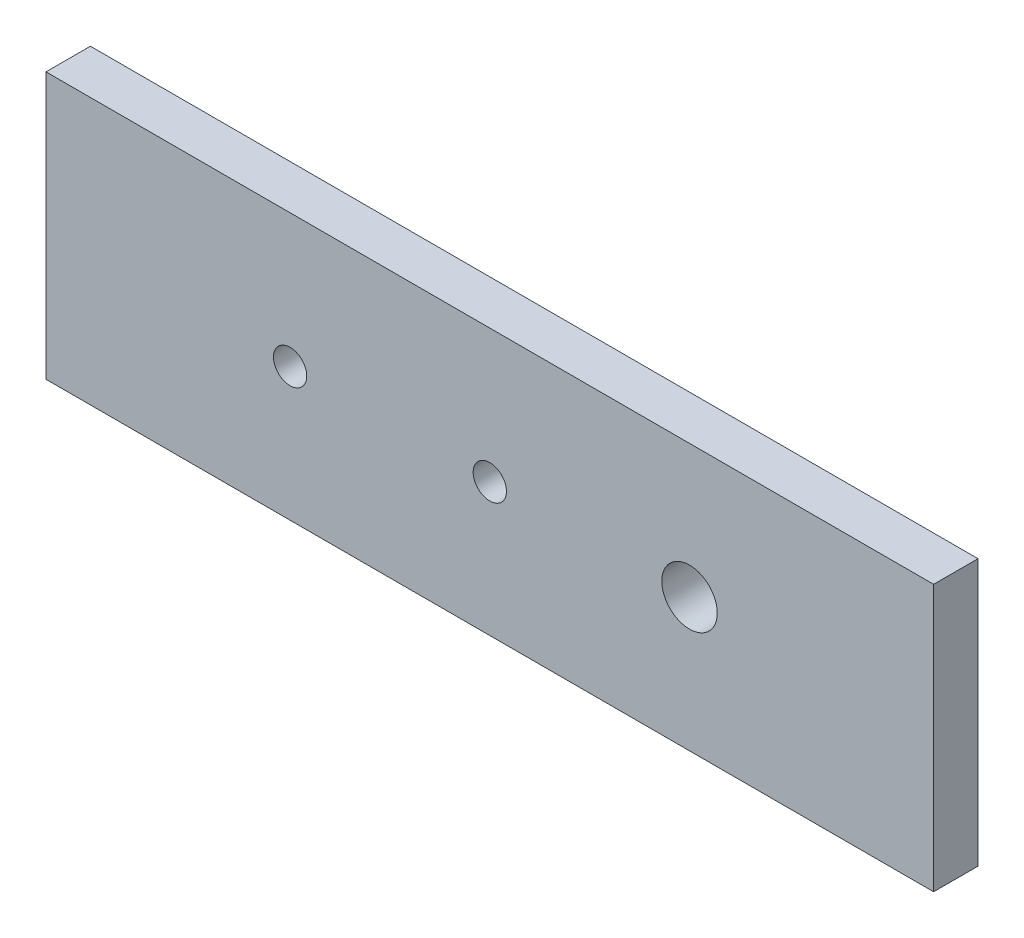
from build123d import *

# Parameters (mm, degrees)
SKETCH1_W           = 508
SKETCH1_H           = 152.4
SKETCH1_R           = 9.525
SKETCH1_R_2         = 15.875
BOSS_EXTRUDE1_DEPTH = 25.4


with BuildPart() as part:
    # Sketch1 → Boss-Extrude1 (new body)
    with BuildSketch(Plane.XY):
        Rectangle(SKETCH1_W, SKETCH1_H)
        with Locations((-114.3, 0)):
            Circle(SKETCH1_R, mode=Mode.SUBTRACT)
        Circle(SKETCH1_R, mode=Mode.SUBTRACT)
        with Locations((114.3, 0)):
            Circle(SKETCH1_R_2, mode=Mode.SUBTRACT)
    extrude(amount=BOSS_EXTRUDE1_DEPTH)


solid = part.part
